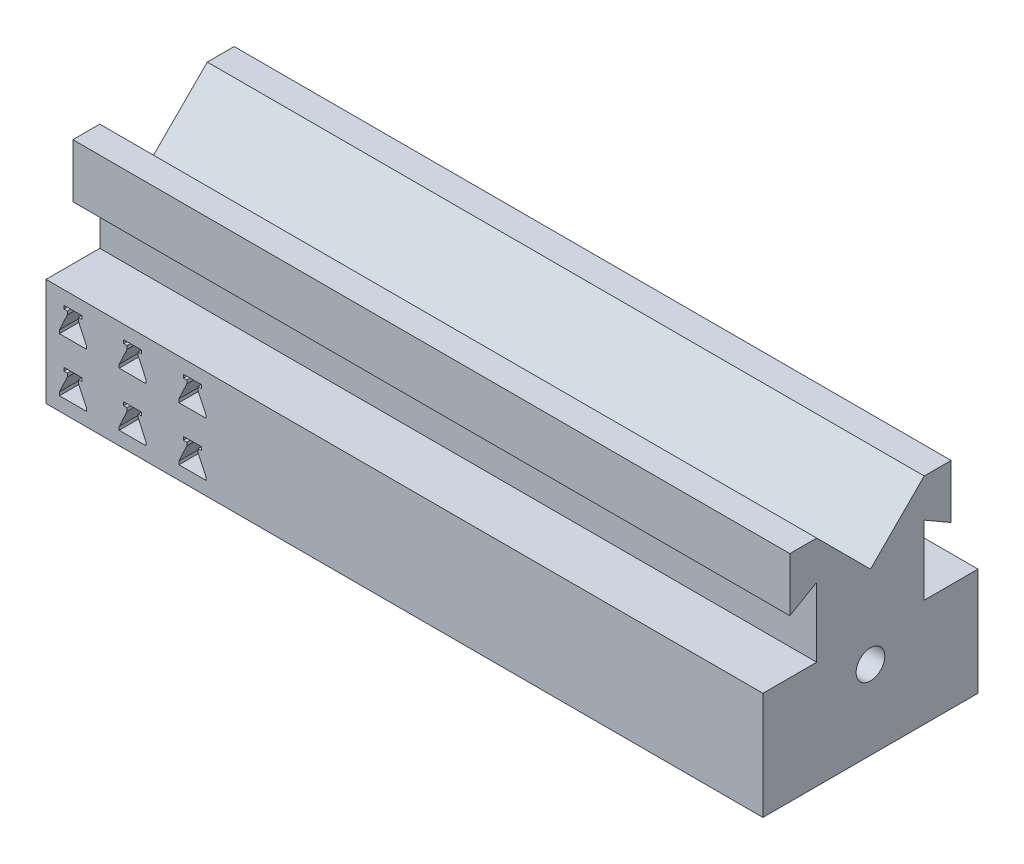
from build123d import *

# Parameters (mm, degrees)
BOSS_EXTRUDE2_DEPTH  = 19.05
BOSS_EXTRUDE1_DEPTH  = 127
SKETCH6_R            = 2.54
CUT_EXTRUDE2_DEPTH   = 128
CUT_EXTRUDE3_DEPTH   = 128
CUT_EXTRUDE4_DEPTH   = 39.1
LPATTERN1_COUNT      = 3
LPATTERN1_PITCH      = 10.583333333
LPATTERN1_COUNT_DIR2 = 2
LPATTERN1_PITCH_DIR2 = 9.525


with BuildPart() as part:
    # Base → Boss-Extrude2 (new body)
    with BuildSketch(Plane(origin=(0, 0, 0), x_dir=(1, 0, 0), z_dir=(0, 1, 0))):
        Polygon((0, 0), (63.5, 0), (122.112570575, 0), (127, 0), (127, -38.1), (31.75, -38.1), (0, -38.1), align=None)
    extrude(amount=BOSS_EXTRUDE2_DEPTH)

    # Sketch3 → Boss-Extrude1 (add)
    with BuildSketch(Plane(origin=(127, 0, 0), x_dir=(0, 0, -1), z_dir=(1, 0, 0))):
        Polygon((-38.1, 38.1), (-28.575, 38.1), (-19.05, 28.575), (-9.525, 38.1), (0, 38.1), (0, 0), (-38.1, 0), align=None)
    extrude(amount=-BOSS_EXTRUDE1_DEPTH)

    # Sketch6 → Cut-Extrude2 (cut, through all)
    with BuildSketch(Plane(origin=(127, 0, 0), x_dir=(0, 0, -1), z_dir=(1, 0, 0))):
        with Locations((-19.05, 13.97)):
            Circle(SKETCH6_R)
    extrude(amount=-CUT_EXTRUDE2_DEPTH, mode=Mode.SUBTRACT)

    # Sketch8 → Cut-Extrude3 (cut, through all)
    with BuildSketch(Plane(origin=(127, 0, 0), x_dir=(0, 0, -1), z_dir=(1, 0, 0))):
        Polygon((-4.7625, 28.575), (-4.7625, 38.1), (0, 38.1), (0, 19.05), (-9.525, 19.05), (-9.525, 31.324630657), align=None)
        Polygon((-28.575, 19.05), (-38.1, 19.05), (-38.1, 38.1), (-33.3375, 38.1), (-33.3375, 28.575), (-28.575, 31.324630657), align=None)
    extrude(amount=-CUT_EXTRUDE3_DEPTH, mode=Mode.SUBTRACT)

    # Sketch9 → Cut-Extrude4 (cut, through all)
    with BuildSketch(Plane.XY.offset(38.1)):
        Polygon((3.175, 16.66875), (6.35, 16.66875), (6.35, 16.0734375), (5.7546875, 16.0734375), (5.7546875, 15.478125), (7.14375, 12.5015625), (7.14375, 11.90625), (2.38125, 11.90625), (2.38125, 12.5015625), (3.7703125, 15.478125), (3.7703125, 16.0734375), (3.175, 16.0734375), align=None)
    cut_extrude4 = extrude(amount=-CUT_EXTRUDE4_DEPTH, mode=Mode.SUBTRACT)

    # LPattern1: Cut-Extrude4 3 × 2
    with Locations(*[(i * LPATTERN1_PITCH, -j * LPATTERN1_PITCH_DIR2, 0) for i in range(LPATTERN1_COUNT) for j in range(LPATTERN1_COUNT_DIR2) if (i, j) != (0, 0)]):
        add(cut_extrude4, mode=Mode.SUBTRACT)


solid = part.part
